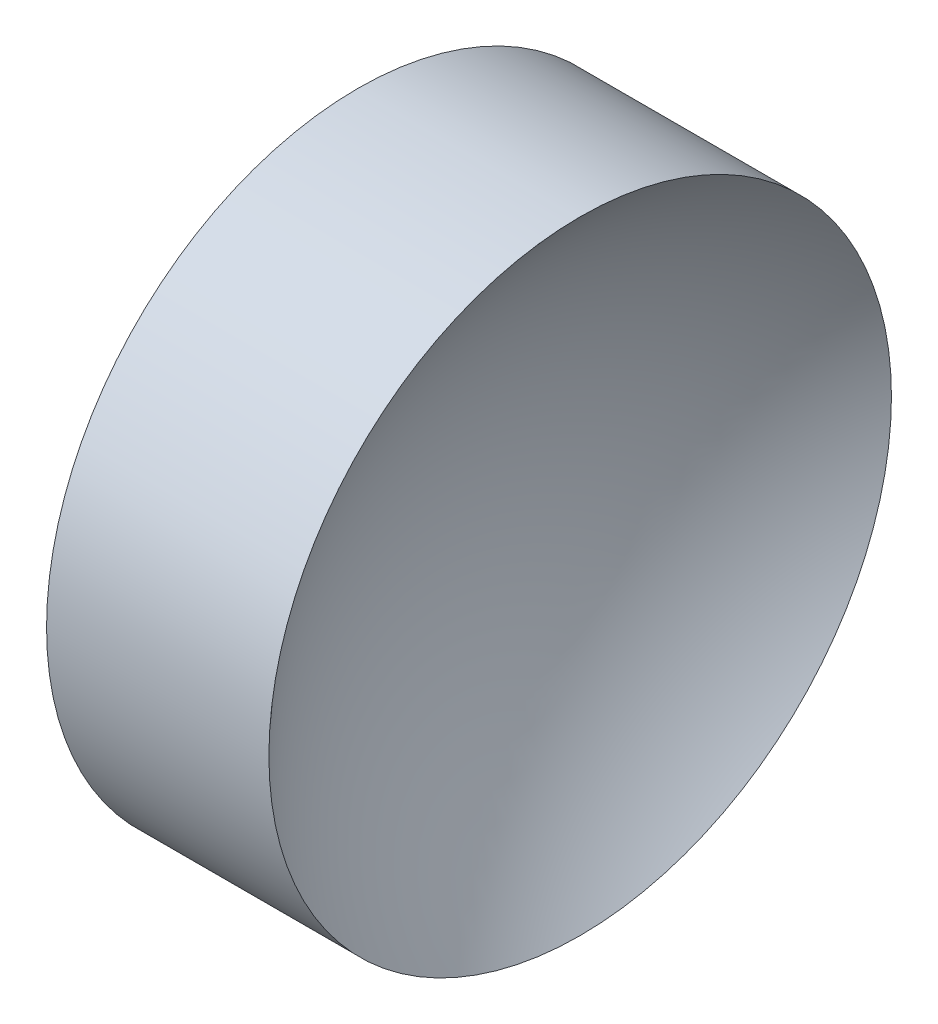
from build123d import *


with BuildPart() as part:
    # 草图1 → 旋转1 (revolve)
    with BuildSketch(Plane.XY, mode=Mode.PRIVATE) as revolve_1_sk:
        with BuildLine():
            Line((22.200875489, 13.031126091), (22.200875489, 16.181126091))
            Line((22.200875489, 16.181126091), (24.450875489, 16.181126091))
            ThreePointArc((24.450875489, 16.181126091), (23.524795162, 14.725602412), (23.200875489, 13.031126091))
            Line((23.200875489, 13.031126091), (22.200875489, 13.031126091))
        make_face()
    revolve(revolve_1_sk.sketch.rotate(Axis((21.156471922, 13.031126091, 0), (1, 0, 0)), 180), axis=Axis((21.156471922, 13.031126091, 0), (1, 0, 0)))  # turned: the seam where the file's is


solid = part.part
